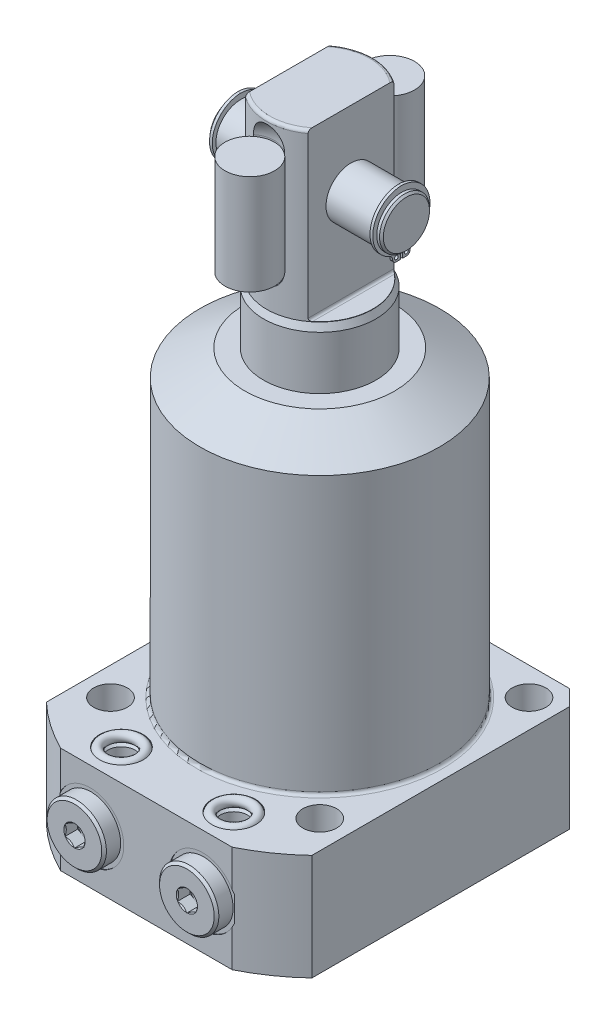
from build123d import *

# Parameters (mm, degrees)
FLATS_DEPTH            = 50
SKETCH23_R             = 0.595
RETAINING_RING_DEPTH   = 0.89
SKETCH24_W             = 7.9375
SKETCH24_H             = 32
SKETCH7_OUTSIDE_W      = 179.488
SKETCH7_OUTSIDE_H      = 179.488
SKETCH7_OUTSIDE_W_2    = 85
SKETCH7_OUTSIDE_H_2    = 98
FLANGE_SIDES_DEPTH     = 35
SKETCH8_R              = 5.4
MOUNTING_HOLES_DEPTH   = 204.2500001
MOUNTING_PATTERN_COUNT = 4
FLANGE_CHAMFER_SIZE    = 5
BODY_FILLET_R          = 1
BSPP_PLUG_HEX_DEPTH    = 4.06
SKETCH16_R             = 1.5


with BuildPart() as part:
    # Sketch1 → PLUNGER (revolve)
    with BuildSketch(Plane.XY, mode=Mode.PRIVATE) as plunger_sk:
        with BuildLine():
            Line((18, 0), (18, 114))
            Line((18, 114), (17, 116.144506921))
            Line((17, 116.144506921), (17, 168.25))
            ThreePointArc((17, 168.25), (16.707106781, 168.957106781), (16, 169.25))
            Line((16, 169.25), (0, 169.25))
            Line((0, 169.25), (0, 0))
            Line((0, 0), (18, 0))
        make_face()
    revolve(plunger_sk.sketch.rotate(Axis((0, -3.075, 0), (0, 1, 0)), 90), axis=Axis((0, -3.075, 0), (0, 1, 0)))  # turned: the seam where the file's is

    # Sketch17 → FLATS (cut, symmetric)
    with BuildSketch(Plane.XY):
        with BuildLine():
            Line((10, 169.25), (17, 169.25))
            Line((17, 169.25), (17, 116.25))
            Line((17, 116.25), (10.8, 116.25))
            ThreePointArc((10.8, 116.25), (10.234314575, 116.484314575), (10, 117.05))
            Line((10, 117.05), (10, 169.25))
        make_face()
        with BuildLine():
            Line((-17, 169.25), (-17, 116.25))
            Line((-17, 116.25), (-10.8, 116.25))
            ThreePointArc((-10.8, 116.25), (-10.234314575, 116.484314575), (-10, 117.05))
            Line((-10, 117.05), (-10, 169.25))
            Line((-10, 169.25), (-17, 169.25))
        make_face()
    extrude(amount=FLATS_DEPTH, both=True, mode=Mode.SUBTRACT)

    # Sketch22 → PIVOT_PIN (revolve)
    with BuildSketch(Plane.XY, mode=Mode.PRIVATE) as pivot_pin_sk:
        Polygon((-27.75, 152.65), (-27.15, 153.25), (-26.25, 153.25), (-26.25, 152.7175), (-25.25, 152.7175), (-25.25, 153.25), (25.25, 153.25), (25.25, 152.7175), (26.25, 152.7175), (26.25, 153.25), (27.15, 153.25), (27.75, 152.65), (27.75, 145.25), (-27.75, 145.25), align=None)
    revolve(pivot_pin_sk.sketch.rotate(Axis((-11.568872367, 145.25, 0), (1, 0, 0)), 90), axis=Axis((-11.568872367, 145.25, 0), (1, 0, 0)))  # turned: the seam where the file's is

    # Sketch23 → RETAINING_RING (add)
    with BuildSketch(Plane(origin=(25.25, 0, 0), x_dir=(0, 0, -1), z_dir=(1, 0, 0))):
        with BuildLine():
            Line((-0.35, 134.70790726), (-1.61, 134.70790726))
            ThreePointArc((-1.61, 134.70790726), (-2.45145707, 135.05645019), (-2.8, 135.89790726))
            ThreePointArc((-2.8, 135.89790726), (-3.016409951, 136.62681713), (-3.595517448, 137.11954157))
            ThreePointArc((-3.595517448, 137.11954157), (-8.984429795, 147.517492161), (0, 155.03))
            ThreePointArc((0, 155.03), (8.984429795, 147.517492161), (3.595517448, 137.11954157))
            ThreePointArc((3.595517448, 137.11954157), (3.016409951, 136.62681713), (2.8, 135.89790726))
            ThreePointArc((2.8, 135.89790726), (2.45145707, 135.05645019), (1.61, 134.70790726))
            Line((1.61, 134.70790726), (0.35, 134.70790726))
            Line((0.35, 134.70790726), (0.35, 137.50790726))
            ThreePointArc((0.35, 137.50790726), (0, 153), (-0.35, 137.50790726))
            Line((-0.35, 137.50790726), (-0.35, 134.70790726))
        make_face()
        with Locations((-1.61, 135.89790726)):
            Circle(SKETCH23_R, mode=Mode.SUBTRACT)
        with Locations(Location((1.61, 135.89790726, 0), (0, 0, 180))):  # turned: the seam where the file's is
            Circle(SKETCH23_R, mode=Mode.SUBTRACT)
    retaining_ring = extrude(amount=RETAINING_RING_DEPTH)

    # RETAINING_RING-OPP: RETAINING_RING across plane
    add(retaining_ring.mirror(Plane.ZY))

    # Sketch20 → SPRING_SLOT (revolve, cut)
    with BuildSketch(Plane.ZY):
        with BuildLine():
            Line((14.5, 161.75), (14.5, 128.75))
            ThreePointArc((14.5, 128.75), (16.824839924, 123.137339924), (22.4375, 120.8125))
            Line((22.4375, 120.8125), (22.4375, 169.6875))
            ThreePointArc((22.4375, 169.6875), (16.824839924, 167.362660076), (14.5, 161.75))
        make_face()
    spring_slot = revolve(axis=Axis((0, 82.047956129, 22.4375), (0, -1, 0)), mode=Mode.SUBTRACT)

    # SPRING_SLOT_OPP: SPRING_SLOT across plane
    add(spring_slot.mirror(Plane.XY), mode=Mode.SUBTRACT)

    # Sketch24 → SPRING (revolve)
    with BuildSketch(Plane.ZY):
        with Locations((-18.43875, 145.25)):
            Rectangle(SKETCH24_W, SKETCH24_H)
    spring = revolve(axis=Axis((0, 84.567834264, -22.4075), (0, -1, 0)))

    # SPRING_OPP: SPRING across plane
    add(spring.mirror(Plane.XY))

    # Sketch6 → BODY_REVOLVE (revolve)
    with BuildSketch(Plane.XY, mode=Mode.PRIVATE) as body_revolve_sk:
        Polygon((0, 97), (24, 97), (38.385, 88.694816378), (38.385, 0), (61.915, 0), (61.915, -34), (0, -34), align=None)
    revolve(body_revolve_sk.sketch.rotate(Axis((0, -34, 0), (0, 1, 0)), 90), axis=Axis((0, -34, 0), (0, 1, 0)))  # turned: the seam where the file's is

    # Sketch7 outside → FLANGE_SIDES (cut, through all)
    with BuildSketch(Plane(origin=(0, 0, 0), x_dir=(-1, 0, 0), z_dir=(0, 1, 0))):
        Rectangle(SKETCH7_OUTSIDE_W, SKETCH7_OUTSIDE_H)
        with Locations((0, 6.5)):
            Rectangle(SKETCH7_OUTSIDE_W_2, SKETCH7_OUTSIDE_H_2, mode=Mode.SUBTRACT)
    extrude(amount=-FLANGE_SIDES_DEPTH, mode=Mode.SUBTRACT)

    # Sketch8 → MOUNTING HOLES (cut, through all)
    with BuildSketch(Plane.XZ.offset(34)):
        with Locations(Location((-33.5, 33.5, 0), (0, 0, 270))):  # turned: the seam where the file's is
            Circle(SKETCH8_R)
    mounting_holes = extrude(amount=-MOUNTING_HOLES_DEPTH, mode=Mode.SUBTRACT)

    # MOUNTING_PATTERN: MOUNTING HOLES ×4 about axis
    mounting_pattern_axis = Axis((0, 0, 0), (0, 1, 0))
    for i in range(1, MOUNTING_PATTERN_COUNT):
        add(mounting_holes.rotate(mounting_pattern_axis, i * 360 / MOUNTING_PATTERN_COUNT), mode=Mode.SUBTRACT)

    # FLANGE_CHAMFER
    flange_chamfer_edges = [part.edges().sort_by_distance(p)[0] for p in [
        (-42.5, -17, -42.5),
        (42.5, -17, -42.5),
    ]]
    chamfer(flange_chamfer_edges, length=FLANGE_CHAMFER_SIZE)

    # BODY_FILLET
    body_fillet_edges = [part.edges().sort_by_distance(p)[0] for p in [
        (0, 0, 38.385),
    ]]
    fillet(body_fillet_edges, radius=BODY_FILLET_R)

    # Sketch11 → PORT SPOT FACE (revolve, cut)
    with BuildSketch(Plane.XZ.offset(17), mode=Mode.PRIVATE) as port_spot_face_sk:
        Polygon((-28.75, 55.5), (-28.75, 55.25), (-24.65, 55.25), (-23.945, 54.545), (-23.945, 36.53), (-18, 36.53), (-18, 55.5), align=None)
    port_spot_face = revolve(port_spot_face_sk.sketch.rotate(Axis((-18, -17, 42.971570338), (0, 0, -1)), 180), axis=Axis((-18, -17, 42.971570338), (0, 0, -1)), mode=Mode.SUBTRACT)  # turned: the seam where the file's is

    # Sketch13 → BOTTOM_MANIFOLD_PORT (revolve, cut)
    with BuildSketch(Plane.XY.offset(45.5)):
        Polygon((-22.375, -22), (-22.375, -31), (-23.125, -31.75), (-25, -31.75), (-25, -34), (-18, -34), (-18, -22), align=None)
    bottom_manifold_port = revolve(axis=Axis((-18, 15.209907045, 45.5), (0, -1, 0)), mode=Mode.SUBTRACT)

    # Sketch14 → BSPP_PLUGHEAD (revolve)
    with BuildSketch(Plane.XZ.offset(17)):
        Polygon((-21.4, 60.55), (-26.75, 60.55), (-27.5, 59.8), (-27.5, 55.25), (-22.125, 55.25), (-22.125, 52.7472), (-18, 52.7472), (-18, 52.7482), (-21, 54.550781857), (-21, 60.15), align=None)
    bspp_plughead = revolve(axis=Axis((-18, -17, 32.588064048), (0, 0, 1)))

    # Sketch15 → BSPP_PLUG_HEX (cut)
    with BuildSketch(Plane.XY.offset(60.55)):
        Polygon((-15, -18.732050808), (-15, -15.267949192), (-18, -13.535898385), (-21, -15.267949192), (-21, -18.732050808), (-18, -20.464101615), align=None)
    bspp_plug_hex = extrude(amount=-BSPP_PLUG_HEX_DEPTH, mode=Mode.SUBTRACT)

    # MANIFOLD_TOP_MIRROR: BOTTOM_MANIFOLD_PORT across plane
    add(bottom_manifold_port.mirror(Plane(origin=(0, -17, 0), x_dir=(0, 0, 1), z_dir=(0, -1, 0))), mode=Mode.SUBTRACT)

    # BSPP-MANIFOLD_MIRROR: PORT SPOT FACE, BOTTOM_MANIFOLD_PORT, BSPP_PLUGHEAD, BSPP_PLUG_HEX across plane
    add(port_spot_face.mirror(Plane(origin=(0, 0, 0), x_dir=(0, 0, 1), z_dir=(1, 0, 0))), mode=Mode.SUBTRACT)
    add(bottom_manifold_port.mirror(Plane(origin=(0, 0, 0), x_dir=(0, 0, 1), z_dir=(1, 0, 0))), mode=Mode.SUBTRACT)
    add(bspp_plughead.mirror(Plane(origin=(0, 0, 0), x_dir=(0, 0, 1), z_dir=(1, 0, 0))))
    add(bspp_plug_hex.mirror(Plane(origin=(0, 0, 0), x_dir=(0, 0, 1), z_dir=(1, 0, 0))), mode=Mode.SUBTRACT)

    # BSPP-MANIFOLD_MIRROR copy 1 sketch → BSPP-MANIFOLD_MIRROR copy 1 (revolve, cut)
    with BuildSketch(Plane(origin=(0, -34, 45.5), x_dir=(-1, 0, 0), z_dir=(0, 0, 1))):
        Polygon((-22.375, -22), (-22.375, -31), (-23.125, -31.75), (-25, -31.75), (-25, -34), (-18, -34), (-18, -22), align=None)
    revolve(axis=Axis((18, -49.209907045, 45.5), (0, 1, 0)), mode=Mode.SUBTRACT)


with BuildPart() as body_2:
    # Sketch16 → MANIFOLD_O-RING (revolve)
    with BuildSketch(Plane.XY.offset(45.5)):
        with Locations((-23.5, -33.25)):
            Circle(SKETCH16_R)
    revolve(axis=Axis((-18, 9.321927472, 45.5), (0, -1, 0)))


with BuildPart() as body_3:
    # MANIFOLD_O-RING_MIRROR: mirrored copy
    add(body_2.part.mirror(Plane(origin=(0, 0, 0), x_dir=(0, 0, 1), z_dir=(1, 0, 0))))


with BuildPart() as body_4:
    # MANIFOLD_O-RING_MIRROR_TOP: mirrored copy
    add(body_2.part.mirror(Plane(origin=(0, -17, 0), x_dir=(0, 0, 1), z_dir=(0, -1, 0))))


with BuildPart() as body_5:
    # MANIFOLD_O-RING_MIRROR_TOP 2: mirrored copy
    add(body_3.part.mirror(Plane(origin=(0, -17, 0), x_dir=(0, 0, 1), z_dir=(0, -1, 0))))


solid = Compound([part.part, body_2.part, body_3.part, body_4.part, body_5.part])
